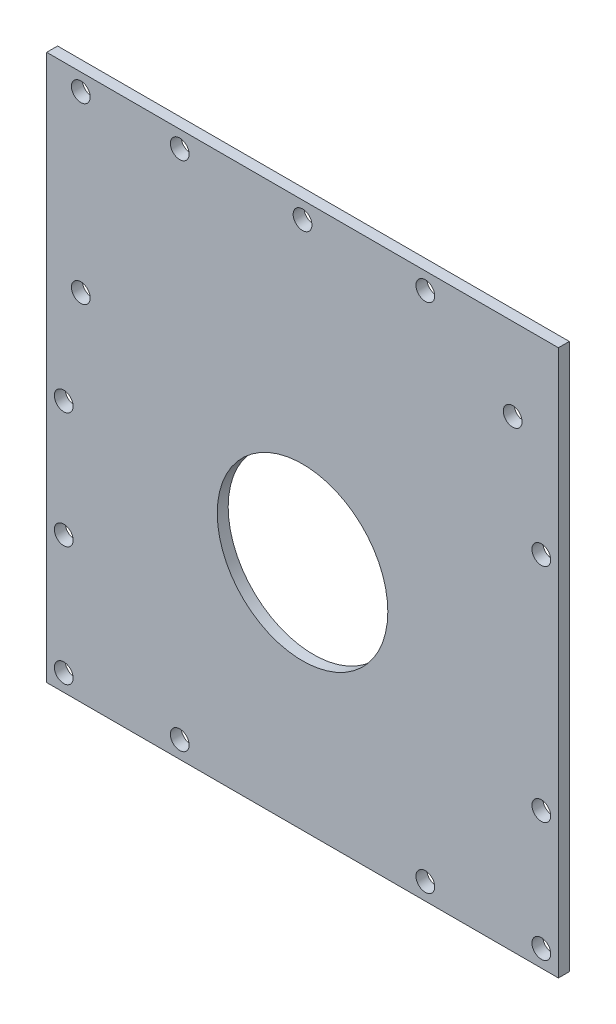
from build123d import *

# Parameters (mm, degrees)
SKETCH1_W           = 150
SKETCH1_H           = 160
BOSS_EXTRUDE1_DEPTH = 3.2
CUT_EXTRUDE1_REACH  = 5.2
SKETCH2_R           = 25
CUT_EXTRUDE2_REACH  = 5.2
SKETCH3_R           = 2.75


with BuildPart() as part:
    # Sketch1 → Boss-Extrude1 (new body)
    with BuildSketch(Plane.XY):
        Rectangle(SKETCH1_W, SKETCH1_H)
    extrude(amount=BOSS_EXTRUDE1_DEPTH)

    # Sketch2 → Cut-Extrude1 (cut, up to next)
    with BuildSketch(Plane.XY.offset(3.2), mode=Mode.PRIVATE) as cut_extrude1_sk1:
        with Locations((0, -12)):
            Circle(SKETCH2_R)
    cut_extrude1_tool1 = extrude(cut_extrude1_sk1.sketch, amount=-CUT_EXTRUDE1_REACH, mode=Mode.PRIVATE) & part.part
    add(cut_extrude1_tool1.solids().sort_by_distance((0, -12, 3.2))[0], mode=Mode.SUBTRACT)

    # Sketch3 → Cut-Extrude2 (cut, up to next)
    with BuildSketch(Plane(origin=(0, 0, 0), x_dir=(-1, 0, 0), z_dir=(0, 0, -1)), mode=Mode.PRIVATE) as cut_extrude2_sk1:
        with Locations((65, 24)):
            Circle(SKETCH3_R)
    cut_extrude2_tool1 = extrude(cut_extrude2_sk1.sketch, amount=-CUT_EXTRUDE2_REACH, mode=Mode.PRIVATE) & part.part
    add(cut_extrude2_tool1.solids().sort_by_distance((-65, 24, 0))[0], mode=Mode.SUBTRACT)
    # Sketch3 → Cut-Extrude2 (cut, up to next)
    with BuildSketch(Plane(origin=(0, 0, 0), x_dir=(-1, 0, 0), z_dir=(0, 0, -1)), mode=Mode.PRIVATE) as cut_extrude2_sk2:
        with Locations((-70, -75)):
            Circle(SKETCH3_R)
    cut_extrude2_tool2 = extrude(cut_extrude2_sk2.sketch, amount=-CUT_EXTRUDE2_REACH, mode=Mode.PRIVATE) & part.part
    add(cut_extrude2_tool2.solids().sort_by_distance((70, -75, 0))[0], mode=Mode.SUBTRACT)
    # Sketch3 → Cut-Extrude2 (cut, up to next)
    with BuildSketch(Plane(origin=(0, 0, 0), x_dir=(-1, 0, 0), z_dir=(0, 0, -1)), mode=Mode.PRIVATE) as cut_extrude2_sk3:
        with Locations((36, -75)):
            Circle(SKETCH3_R)
    cut_extrude2_tool3 = extrude(cut_extrude2_sk3.sketch, amount=-CUT_EXTRUDE2_REACH, mode=Mode.PRIVATE) & part.part
    add(cut_extrude2_tool3.solids().sort_by_distance((-36, -75, 0))[0], mode=Mode.SUBTRACT)
    # Sketch3 → Cut-Extrude2 (cut, up to next)
    with BuildSketch(Plane(origin=(0, 0, 0), x_dir=(-1, 0, 0), z_dir=(0, 0, -1)), mode=Mode.PRIVATE) as cut_extrude2_sk4:
        with Locations((-36, -75)):
            Circle(SKETCH3_R)
    cut_extrude2_tool4 = extrude(cut_extrude2_sk4.sketch, amount=-CUT_EXTRUDE2_REACH, mode=Mode.PRIVATE) & part.part
    add(cut_extrude2_tool4.solids().sort_by_distance((36, -75, 0))[0], mode=Mode.SUBTRACT)
    # Sketch3 → Cut-Extrude2 (cut, up to next)
    with BuildSketch(Plane(origin=(0, 0, 0), x_dir=(-1, 0, 0), z_dir=(0, 0, -1)), mode=Mode.PRIVATE) as cut_extrude2_sk5:
        with Locations((70, -75)):
            Circle(SKETCH3_R)
    cut_extrude2_tool5 = extrude(cut_extrude2_sk5.sketch, amount=-CUT_EXTRUDE2_REACH, mode=Mode.PRIVATE) & part.part
    add(cut_extrude2_tool5.solids().sort_by_distance((-70, -75, 0))[0], mode=Mode.SUBTRACT)
    # Sketch3 → Cut-Extrude2 (cut, up to next)
    with BuildSketch(Plane(origin=(0, 0, 0), x_dir=(-1, 0, 0), z_dir=(0, 0, -1)), mode=Mode.PRIVATE) as cut_extrude2_sk6:
        with Locations((-70, -40)):
            Circle(SKETCH3_R)
    cut_extrude2_tool6 = extrude(cut_extrude2_sk6.sketch, amount=-CUT_EXTRUDE2_REACH, mode=Mode.PRIVATE) & part.part
    add(cut_extrude2_tool6.solids().sort_by_distance((70, -40, 0))[0], mode=Mode.SUBTRACT)
    # Sketch3 → Cut-Extrude2 (cut, up to next)
    with BuildSketch(Plane(origin=(0, 0, 0), x_dir=(-1, 0, 0), z_dir=(0, 0, -1)), mode=Mode.PRIVATE) as cut_extrude2_sk7:
        with Locations((-70, 25)):
            Circle(SKETCH3_R)
    cut_extrude2_tool7 = extrude(cut_extrude2_sk7.sketch, amount=-CUT_EXTRUDE2_REACH, mode=Mode.PRIVATE) & part.part
    add(cut_extrude2_tool7.solids().sort_by_distance((70, 25, 0))[0], mode=Mode.SUBTRACT)
    # Sketch3 → Cut-Extrude2 (cut, up to next)
    with BuildSketch(Plane(origin=(0, 0, 0), x_dir=(-1, 0, 0), z_dir=(0, 0, -1)), mode=Mode.PRIVATE) as cut_extrude2_sk8:
        with Locations((-36, 75)):
            Circle(SKETCH3_R)
    cut_extrude2_tool8 = extrude(cut_extrude2_sk8.sketch, amount=-CUT_EXTRUDE2_REACH, mode=Mode.PRIVATE) & part.part
    add(cut_extrude2_tool8.solids().sort_by_distance((36, 75, 0))[0], mode=Mode.SUBTRACT)
    # Sketch3 → Cut-Extrude2 (cut, up to next)
    with BuildSketch(Plane(origin=(0, 0, 0), x_dir=(-1, 0, 0), z_dir=(0, 0, -1)), mode=Mode.PRIVATE) as cut_extrude2_sk9:
        with Locations((36, 75)):
            Circle(SKETCH3_R)
    cut_extrude2_tool9 = extrude(cut_extrude2_sk9.sketch, amount=-CUT_EXTRUDE2_REACH, mode=Mode.PRIVATE) & part.part
    add(cut_extrude2_tool9.solids().sort_by_distance((-36, 75, 0))[0], mode=Mode.SUBTRACT)
    # Sketch3 → Cut-Extrude2 (cut, up to next)
    with BuildSketch(Plane(origin=(0, 0, 0), x_dir=(-1, 0, 0), z_dir=(0, 0, -1)), mode=Mode.PRIVATE) as cut_extrude2_sk10:
        with Locations((65, 75)):
            Circle(SKETCH3_R)
    cut_extrude2_tool10 = extrude(cut_extrude2_sk10.sketch, amount=-CUT_EXTRUDE2_REACH, mode=Mode.PRIVATE) & part.part
    add(cut_extrude2_tool10.solids().sort_by_distance((-65, 75, 0))[0], mode=Mode.SUBTRACT)
    # Sketch3 → Cut-Extrude2 (cut, up to next)
    with BuildSketch(Plane(origin=(0, 0, 0), x_dir=(-1, 0, 0), z_dir=(0, 0, -1)), mode=Mode.PRIVATE) as cut_extrude2_sk11:
        with Locations((70, -40)):
            Circle(SKETCH3_R)
    cut_extrude2_tool11 = extrude(cut_extrude2_sk11.sketch, amount=-CUT_EXTRUDE2_REACH, mode=Mode.PRIVATE) & part.part
    add(cut_extrude2_tool11.solids().sort_by_distance((-70, -40, 0))[0], mode=Mode.SUBTRACT)
    # Sketch3 → Cut-Extrude2 (cut, up to next)
    with BuildSketch(Plane(origin=(0, 0, 0), x_dir=(-1, 0, 0), z_dir=(0, 0, -1)), mode=Mode.PRIVATE) as cut_extrude2_sk12:
        with Locations((70, -6)):
            Circle(SKETCH3_R)
    cut_extrude2_tool12 = extrude(cut_extrude2_sk12.sketch, amount=-CUT_EXTRUDE2_REACH, mode=Mode.PRIVATE) & part.part
    add(cut_extrude2_tool12.solids().sort_by_distance((-70, -6, 0))[0], mode=Mode.SUBTRACT)
    # Sketch3 → Cut-Extrude2 (cut, up to next)
    with BuildSketch(Plane(origin=(0, 0, 0), x_dir=(-1, 0, 0), z_dir=(0, 0, -1)), mode=Mode.PRIVATE) as cut_extrude2_sk13:
        with Locations((0, 75)):
            Circle(SKETCH3_R)
    cut_extrude2_tool13 = extrude(cut_extrude2_sk13.sketch, amount=-CUT_EXTRUDE2_REACH, mode=Mode.PRIVATE) & part.part
    add(cut_extrude2_tool13.solids().sort_by_distance((0, 75, 0))[0], mode=Mode.SUBTRACT)
    # Sketch3 → Cut-Extrude2 (cut, up to next)
    with BuildSketch(Plane(origin=(0, 0, 0), x_dir=(-1, 0, 0), z_dir=(0, 0, -1)), mode=Mode.PRIVATE) as cut_extrude2_sk14:
        with Locations((-61.592770869, 55.875856237)):
            Circle(SKETCH3_R)
    cut_extrude2_tool14 = extrude(cut_extrude2_sk14.sketch, amount=-CUT_EXTRUDE2_REACH, mode=Mode.PRIVATE) & part.part
    add(cut_extrude2_tool14.solids().sort_by_distance((61.592771, 55.875856, 0))[0], mode=Mode.SUBTRACT)


solid = part.part
